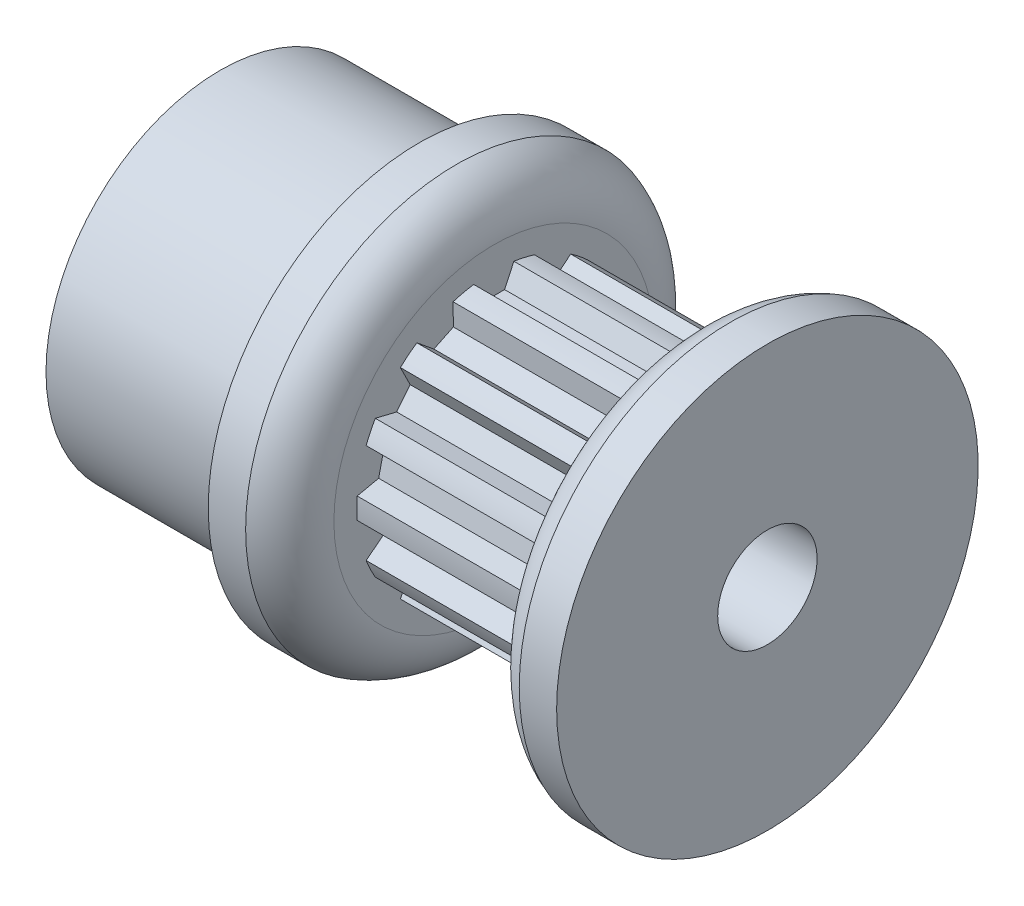
from build123d import *

# Parameters (mm, degrees)
SKETCH4_R          = 4.5339
SKETCH4_R_2        = 4.37515
CUT_EXTRUDE2_DEPTH = 6.35
CUT_EXTRUDE1_DEPTH = 6.35
CIRPATTERN1_COUNT  = 14


with BuildPart() as part:
    # Sketch1 → Revolve1 (revolve)
    with BuildSketch(Plane.XY, mode=Mode.PRIVATE) as revolve1_sk:
        with BuildLine():
            Line((-8.7376, 1.5875), (8.7376, 1.5875))
            Line((8.7376, 1.5875), (8.7376, 6.731))
            Line((8.7376, 6.731), (7.5438, 6.731))
            ThreePointArc((7.5438, 6.731), (6.680508602, 6.113831183), (6.35, 5.1054))
            Line((6.35, 5.1054), (6.35, 4.5339))
            Line((6.35, 4.5339), (0, 4.5339))
            Line((0, 4.5339), (0, 5.1054))
            ThreePointArc((0, 5.1054), (-0.330508602, 6.113831183), (-1.1938, 6.731))
            Line((-1.1938, 6.731), (-2.3876, 6.731))
            Line((-2.3876, 6.731), (-2.3876, 5.5626))
            Line((-2.3876, 5.5626), (-8.7376, 5.5626))
            Line((-8.7376, 5.5626), (-8.7376, 1.5875))
        make_face()
    revolve(revolve1_sk.sketch.rotate(Axis((-8.7376, 0, 0), (1, 0, 0)), 90), axis=Axis((-8.7376, 0, 0), (1, 0, 0)))

    # Sketch4 → Cut-Extrude2 (cut)
    with BuildSketch(Plane(origin=(0, 0, 0), x_dir=(0, 0, -1), z_dir=(1, 0, 0))):
        Circle(SKETCH4_R)
        Circle(SKETCH4_R_2, mode=Mode.SUBTRACT)
    extrude(amount=CUT_EXTRUDE2_DEPTH, mode=Mode.SUBTRACT)

    # Sketch3 → Cut-Extrude1 (cut)
    with BuildSketch(Plane(origin=(0, 0, 0), x_dir=(0, 0, -1), z_dir=(1, 0, 0))):
        with BuildLine():
            Line((-0.641613493, 4.327848154), (-0.345249615, 3.692293767))
            Line((-0.345249615, 3.692293767), (0.345249615, 3.692293767))
            Line((0.345249615, 3.692293767), (0.641613493, 4.327848154))
            ThreePointArc((0.641613493, 4.327848154), (0, 4.37515), (-0.641613493, 4.327848154))
        make_face()
    cut_extrude1 = extrude(amount=CUT_EXTRUDE1_DEPTH, mode=Mode.SUBTRACT)

    # CirPattern1: Cut-Extrude1 ×14 about axis
    cirpattern1_axis = Axis((0, 0, 0), (1, 0, 0))
    for i in range(1, CIRPATTERN1_COUNT):
        add(cut_extrude1.rotate(cirpattern1_axis, i * 360 / CIRPATTERN1_COUNT), mode=Mode.SUBTRACT)


solid = part.part
